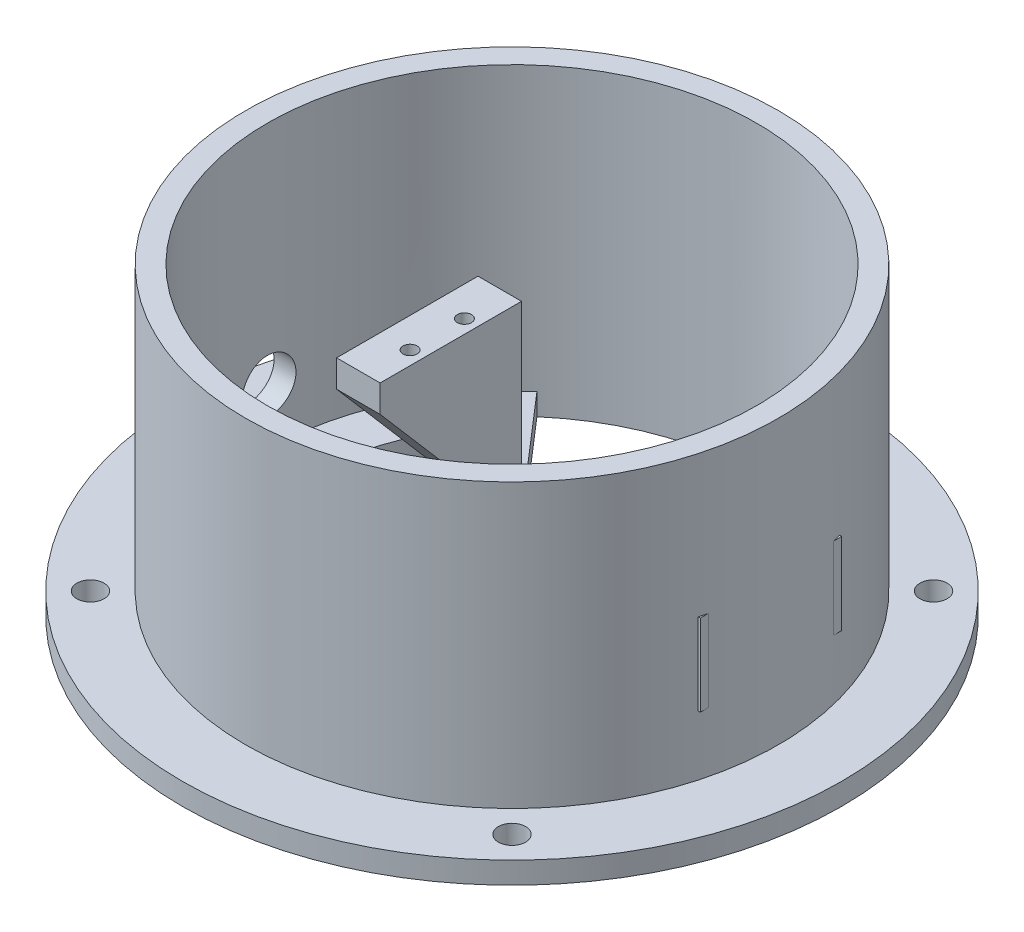
from build123d import *

# Parameters (mm, degrees)
IZIM7_W                     = 26
IZIM7_H                     = 8
Y_KSEKLIK_EKSTR_ZYON3_DEPTH = 15
IZIM8_W                     = 8
IZIM8_H                     = 26
Y_KSEKLIK_EKSTR_ZYON4_DEPTH = 4
IZIM9_W                     = 8
IZIM9_H                     = 26
Y_KSEKLIK_EKSTR_ZYON5_DEPTH = 38
IZIM11_R                    = 5
KES_EKSTR_ZYON1_DEPTH       = 44
IZIM12_R                    = 2.5
KES_EKSTR_ZYON2_DEPTH       = 44
IZIM14_R                    = 1.3
KES_EKSTR_ZYON3_DEPTH       = 4
KES_EKSTR_ZYON4_DEPTH       = 10
Y_KSEKLIK_EKSTR_ZYON6_DEPTH = 26
KES_EKSTR_ZYON5_DEPTH       = 30
Y_KSEKLIK_EKSTR_ZYON7_DEPTH = 26
Y_KSEKLIK_EKSTR_ZYON8_DEPTH = 26
KES_EKSTR_ZYON6_DEPTH       = 26


with BuildPart() as part:
    # Çizim1 → Döndür5 (revolve)
    with BuildSketch(Plane.XY, mode=Mode.PRIVATE) as d_nd_r5_sk:
        Polygon((49, 4), (60.625, 4), (60.625, 0), (45, 0), (45, 56), (49, 56), align=None)
    revolve(d_nd_r5_sk.sketch.rotate(Axis((0, 14.385693044, 0), (0, -1, 0)), 90), axis=Axis((0, 14.385693044, 0), (0, -1, 0)))

    # Çizim7 → Yükseklik-Ekstrüzyon3 (add)
    with BuildSketch(Plane.ZY.offset(-45)):
        with Locations((0, 34)):
            Rectangle(IZIM7_W, IZIM7_H)
    extrude(amount=Y_KSEKLIK_EKSTR_ZYON3_DEPTH)

    # Çizim8 → Yükseklik-Ekstrüzyon4 (add)
    with BuildSketch(Plane(origin=(0, 0, 0), x_dir=(1, 0, 0), z_dir=(0, 1, 0))):
        with Locations((-15.25, 0)):
            Rectangle(IZIM8_W, IZIM8_H)
        with BuildLine():
            Line((-11.25, 13), (-29.4469535, 34.027590711))
            ThreePointArc((-29.4469535, 34.027590711), (-45, 0), (-29.4469535, -34.027590711))
            Line((-29.4469535, -34.027590711), (-11.25, -13))
            Line((-11.25, -13), (-19.25, -13))
            Line((-19.25, -13), (-19.25, 13))
            Line((-19.25, 13), (-11.25, 13))
        make_face()
        with BuildLine():
            ThreePointArc((-29.4469535, 22.402609883), (-36.999521245, 0.188222241), (-29.673354544, -22.101855807))
            Line((-29.673354544, -22.101855807), (-24.25, -15.834868333))
            Line((-24.25, -15.834868333), (-24.25, 15.394791201))
            Line((-24.25, 15.394791201), (-29.4469535, 22.402609883))
        make_face(mode=Mode.SUBTRACT)
    extrude(amount=Y_KSEKLIK_EKSTR_ZYON4_DEPTH)

    # Çizim9 → Yükseklik-Ekstrüzyon5 (add)
    with BuildSketch(Plane(origin=(0, 0, 0), x_dir=(1, 0, 0), z_dir=(0, 1, 0))):
        with Locations((-15.25, 0)):
            Rectangle(IZIM9_W, IZIM9_H)
    extrude(amount=Y_KSEKLIK_EKSTR_ZYON5_DEPTH)

    # Çizim11 → Kes-Ekstrüzyon1 (cut)
    with BuildSketch(Plane.ZY.offset(19.25)):
        with Locations(Location((0, 14, 0), (0, 0, 180))):
            Circle(IZIM11_R)
    extrude(amount=KES_EKSTR_ZYON1_DEPTH, mode=Mode.SUBTRACT)

    # Çizim12 → Kes-Ekstrüzyon2 (cut)
    with BuildSketch(Plane(origin=(0, 0, 0), x_dir=(1, 0, 0), z_dir=(0, 1, 0))):
        with Locations(Location((-38.756522677, 38.756522677, 0), (0, 0, 270))):
            Circle(IZIM12_R)
        with Locations(Location((38.756522677, 38.756522677, 0), (0, 0, 270))):
            Circle(IZIM12_R)
        with Locations(Location((-38.756522677, -38.756522677, 0), (0, 0, 270))):
            Circle(IZIM12_R)
        with Locations(Location((38.756522677, -38.756522677, 0), (0, 0, 270))):
            Circle(IZIM12_R)
    extrude(amount=KES_EKSTR_ZYON2_DEPTH, mode=Mode.SUBTRACT)

    # Çizim14 → Kes-Ekstrüzyon3 (cut)
    with BuildSketch(Plane(origin=(0, 38, 0), x_dir=(1, 0, 0), z_dir=(0, 1, 0))):
        with Locations(Location((-13.75, 5, 0), (0, 0, 270))):
            Circle(IZIM14_R)
        with Locations(Location((-13.75, -5, 0), (0, 0, 270))):
            Circle(IZIM14_R)
        with Locations(Location((34.25, -5, 0), (0, 0, 270))):
            Circle(IZIM14_R)
        with Locations(Location((34.25, 5, 0), (0, 0, 270))):
            Circle(IZIM14_R)
    extrude(amount=-KES_EKSTR_ZYON3_DEPTH, mode=Mode.SUBTRACT)

    # Çizim15 → Kes-Ekstrüzyon4 (cut)
    with BuildSketch(Plane.ZY.offset(19.25)):
        Polygon((13, 30.072092804), (-5.072092804, 12), (13, 12), align=None)
    extrude(amount=-KES_EKSTR_ZYON4_DEPTH, mode=Mode.SUBTRACT)

    # Çizim16 → Yükseklik-Ekstrüzyon6 (add)
    with BuildSketch(Plane.XY.offset(13)):
        Polygon((30, 30), (45.409856654, 14.590143346), (45.409856654, 30), align=None)
    extrude(amount=-Y_KSEKLIK_EKSTR_ZYON6_DEPTH)

    # Çizim17 → Kes-Ekstrüzyon5 (cut)
    with BuildSketch(Plane(origin=(0, 0, 0), x_dir=(1, 0, 0), z_dir=(0, 1, 0))):
        with BuildLine():
            Line((0, -45), (0, 45))
            ThreePointArc((0, 45), (45, 0), (0, -45))
        make_face()
    extrude(amount=KES_EKSTR_ZYON5_DEPTH, mode=Mode.SUBTRACT)

    # Çizim18 → Yükseklik-Ekstrüzyon7 (add)
    with BuildSketch(Plane.XY.offset(13)):
        Polygon((43.081318457, 30), (30, 30), (45, 15), (47.625193475, 15), (47.625193475, 30), align=None)
    extrude(amount=-Y_KSEKLIK_EKSTR_ZYON7_DEPTH)

    # Çizim19 → Yükseklik-Ekstrüzyon8 (add)
    with BuildSketch(Plane.XY.offset(13)):
        Polygon((30, 30), (45, 7.621420501), (46.501965359, 7.621420501), (46.501965359, 30), align=None)
    extrude(amount=-Y_KSEKLIK_EKSTR_ZYON8_DEPTH)

    # Çizim20 → Kes-Ekstrüzyon6 (cut)
    with BuildSketch(Plane.ZY.offset(19.25)):
        Polygon((13, 33), (-5.072092804, 12), (13, 12), align=None)
    extrude(amount=-KES_EKSTR_ZYON6_DEPTH, mode=Mode.SUBTRACT)


solid = part.part
